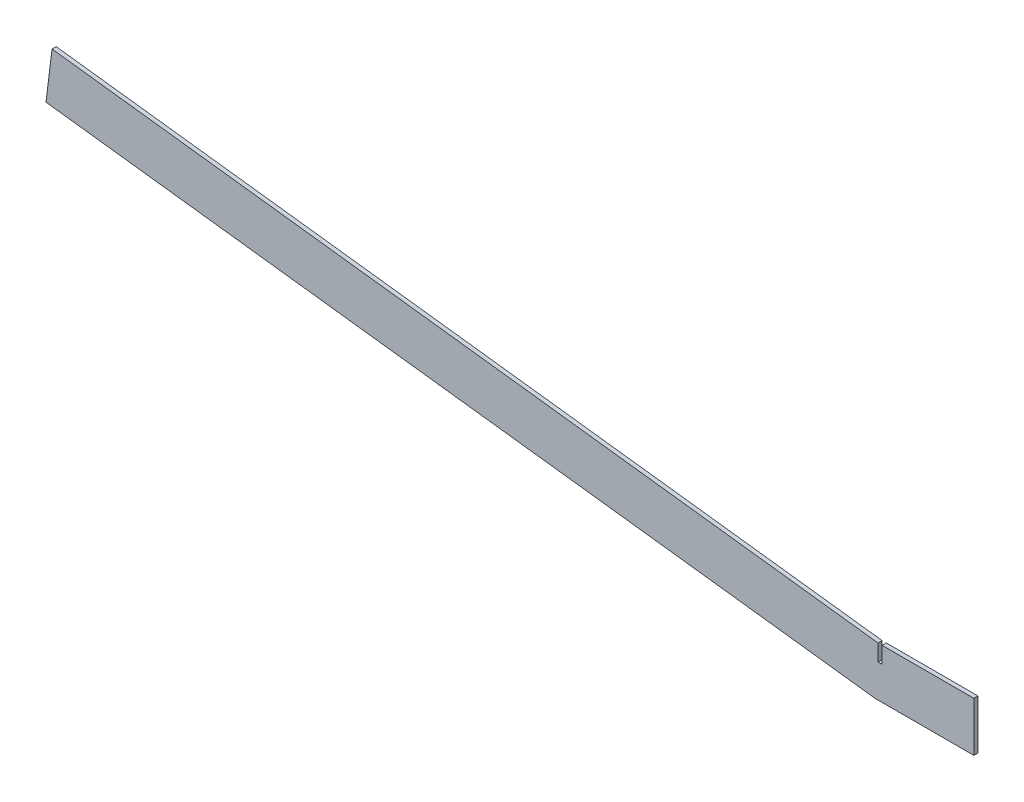
from build123d import *

# Parameters (mm, degrees)
BOSS_EXTRUDE1_DEPTH = 1.5875


with BuildPart() as part:
    # Sketch1 → Boss-Extrude1 (new body, symmetric)
    with BuildSketch(Plane.XY):
        Polygon((-638.481007022, 78.395610092), (0, 0), (76.2, 0), (76.2, 38.1), (5.505295828, 38.1), (5.505295828, 25.4), (2.330295828, 25.4), (2.330295828, 38.1), (-633.837785039, 116.21161847), align=None)
    extrude(amount=BOSS_EXTRUDE1_DEPTH, both=True)


solid = part.part
